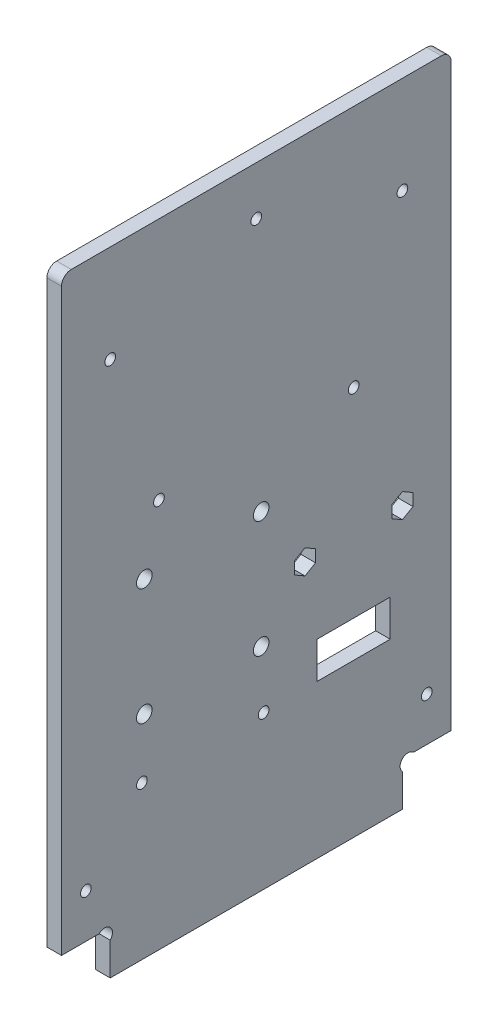
from build123d import *

# Parameters (mm, degrees)
EXTRUSION1_DEPTH        = 3
ESQUISSE2_R             = 1.1
ESQUISSE2_R_2           = 1.6
ENL_V_MAT_EXTRU_1_DEPTH = 4
ESQUISSE3_W             = 15
ESQUISSE3_H             = 7.5
ENL_V_MAT_EXTRU_2_DEPTH = 4
ESQUISSE4_R             = 1.1
ENL_V_MAT_EXTRU_3_DEPTH = 4
ENL_V_MAT_EXTRU_4_DEPTH = 4
CONG_1_R                = 2
ESQUISSE6_R             = 1.1
ENL_V_MAT_EXTRU_5_DEPTH = 4


with BuildPart() as part:
    # Esquisse1 → Extrusion1 (new body)
    with BuildSketch(Plane(origin=(0, 0, 0), x_dir=(0, 0, -1), z_dir=(1, 0, 0))):
        with BuildLine():
            Line((10, 6.7372583), (10, 0))
            Line((10, 0), (70, 0))
            Line((70, 0), (70, 6.7372583))
            ThreePointArc((70, 6.7372583), (70, 9), (72.2627417, 9))
            Line((72.2627417, 9), (80, 9))
            Line((80, 9), (80, 130))
            Line((80, 130), (0, 130))
            Line((0, 130), (0, 9))
            Line((0, 9), (7.7372583, 9))
            ThreePointArc((7.7372583, 9), (10, 9), (10, 6.7372583))
        make_face()
    extrude(amount=EXTRUSION1_DEPTH)

    # Esquisse2 → Enlèv. mat.-Extru.1 (cut, through all)
    with BuildSketch(Plane(origin=(3, 0, 0), x_dir=(0, 0, -1), z_dir=(1, 0, 0))):
        with Locations((60, 80)):
            Circle(ESQUISSE2_R)
        with Locations((10, 110)):
            Circle(ESQUISSE2_R)
        with Locations(Location((20, 80, 0), (0, 0, 180))):  # turned: the seam where the file's is
            Circle(ESQUISSE2_R)
        with Locations((70, 110)):
            Circle(ESQUISSE2_R)
        with Locations((17, 67.45)):
            Circle(ESQUISSE2_R_2)
        with Locations((17, 43.45)):
            Circle(ESQUISSE2_R_2)
        with Locations((41, 43.45)):
            Circle(ESQUISSE2_R_2)
        with Locations((41, 67.45)):
            Circle(ESQUISSE2_R_2)
        with Locations((40, 120)):
            Circle(ESQUISSE2_R)
        with Locations((70, 54)):
            Circle(ESQUISSE2_R)
        with Locations((50, 54)):
            Circle(ESQUISSE2_R)
    extrude(amount=-ENL_V_MAT_EXTRU_1_DEPTH, mode=Mode.SUBTRACT)

    # Esquisse3 → Enlèv. mat.-Extru.2 (cut, through all)
    with BuildSketch(Plane.ZY):
        with Locations((-60, 35.25)):
            Rectangle(ESQUISSE3_W, ESQUISSE3_H)
    extrude(amount=-ENL_V_MAT_EXTRU_2_DEPTH, mode=Mode.SUBTRACT)

    # Esquisse4 → Enlèv. mat.-Extru.3 (cut, through all)
    with BuildSketch(Plane(origin=(3, 0, 0), x_dir=(0, 0, -1), z_dir=(1, 0, 0))):
        with Locations((75, 18)):
            Circle(ESQUISSE4_R)
        with Locations((5, 18)):
            Circle(ESQUISSE4_R)
    extrude(amount=-ENL_V_MAT_EXTRU_3_DEPTH, mode=Mode.SUBTRACT)

    # Esquisse5 → Enlèv. mat.-Extru.4 (cut, through all)
    with BuildSketch(Plane(origin=(3, 0, 0), x_dir=(0, 0, -1), z_dir=(1, 0, 0))):
        Polygon((50, 51.5), (52.165063509, 52.75), (52.165063509, 55.25), (50, 56.5), (47.834936491, 55.25), (47.834936491, 52.75), align=None)
        Polygon((70, 51.5), (72.165063509, 52.75), (72.165063509, 55.25), (70, 56.5), (67.834936491, 55.25), (67.834936491, 52.75), align=None)
    extrude(amount=-ENL_V_MAT_EXTRU_4_DEPTH, mode=Mode.SUBTRACT)

    # Congé1
    cong_1_edges = [part.edges().sort_by_distance(p)[0] for p in [
        (1.5, 130, 0),
        (1.5, 130, -80),
    ]]
    fillet(cong_1_edges, radius=CONG_1_R)

    # Esquisse6 → Enlèv. mat.-Extru.5 (cut, through all)
    with BuildSketch(Plane(origin=(3, 0, 0), x_dir=(0, 0, -1), z_dir=(1, 0, 0))):
        with Locations((16.5, 31.460421192)):
            Circle(ESQUISSE6_R)
        with Locations((41.5, 31.460421192)):
            Circle(ESQUISSE6_R)
    extrude(amount=-ENL_V_MAT_EXTRU_5_DEPTH, mode=Mode.SUBTRACT)


solid = part.part
